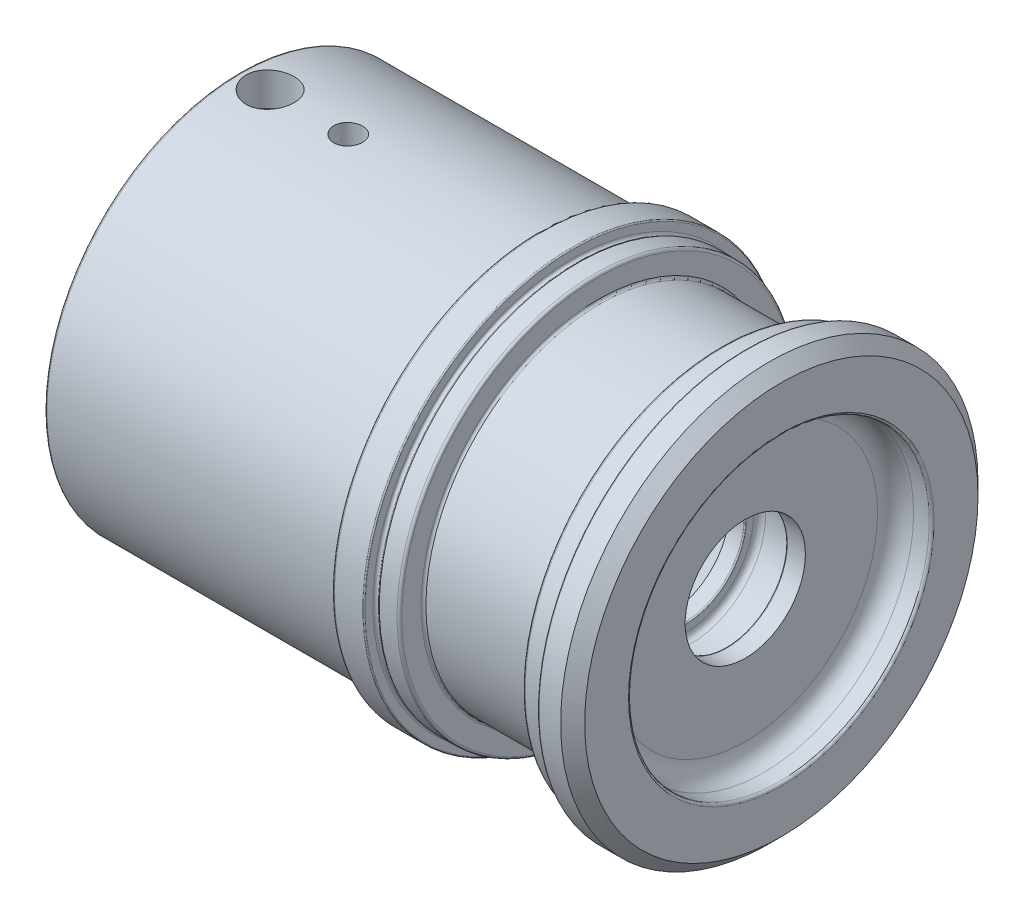
from build123d import *

# Parameters (mm, degrees)
SKETCH2_R          = 4
CUT_EXTRUDE2_DEPTH = 40.5
SKETCH3_R          = 2.4
CUT_EXTRUDE3_DEPTH = 40.5


with BuildPart() as part:
    # Sketch1 → Base-Revolve (revolve)
    with BuildSketch(Plane.XY):
        with BuildLine():
            Line((0, 25.4), (0, 32.7))
            Line((0, 32.7), (-2, 34.7))
            Line((-2, 34.7), (-5.6, 34.7))
            ThreePointArc((-5.6, 34.7), (-5.741421356, 34.641421356), (-5.8, 34.5))
            Line((-5.8, 34.5), (-5.8, 33.2))
            ThreePointArc((-5.8, 33.2), (-6, 32.853589838), (-6.4, 32.853589838))
            Line((-6.4, 32.853589838), (-6.653589838, 33))
            Line((-6.653589838, 33), (-9.6, 33))
            ThreePointArc((-9.6, 33), (-9.882842712, 32.882842712), (-10, 32.6))
            Line((-10, 32.6), (-10, 29.4))
            ThreePointArc((-10, 29.4), (-10.117157288, 29.117157288), (-10.4, 29))
            Line((-10.4, 29), (-30.1, 29))
            ThreePointArc((-30.1, 29), (-30.382842712, 29.117157288), (-30.5, 29.4))
            Line((-30.5, 29.4), (-30.5, 32.6))
            ThreePointArc((-30.5, 32.6), (-30.617157288, 32.882842712), (-30.9, 33))
            Line((-30.9, 33), (-33.846410162, 33))
            Line((-33.846410162, 33), (-34.1, 32.853589838))
            ThreePointArc((-34.1, 32.853589838), (-34.5, 32.853589838), (-34.7, 33.2))
            Line((-34.7, 33.2), (-34.7, 34.5))
            ThreePointArc((-34.7, 34.5), (-34.758578644, 34.641421356), (-34.9, 34.7))
            Line((-34.9, 34.7), (-39.6, 34.7))
            ThreePointArc((-39.6, 34.7), (-39.882842712, 34.582842712), (-40, 34.3))
            Line((-40, 34.3), (-40, 32.9))
            ThreePointArc((-40, 32.9), (-40.117157288, 32.617157288), (-40.4, 32.5))
            Line((-40.4, 32.5), (-89.6, 32.5))
            ThreePointArc((-89.6, 32.5), (-89.882842712, 32.382842712), (-90, 32.1))
            Line((-90, 32.1), (-90, 27.4))
            ThreePointArc((-90, 27.4), (-89.882842712, 27.117157288), (-89.6, 27))
            Line((-89.6, 27), (-80, 27))
            Line((-80, 27), (-80, 25))
            Line((-80, 25), (-63, 25))
            Line((-63, 25), (-59.393004193, 22.9175))
            Line((-59.393004193, 22.9175), (-29.723131212, 22.9175))
            Line((-29.723131212, 22.9175), (-29, 22.5))
            Line((-29, 22.5), (-23.4, 22.5))
            ThreePointArc((-23.4, 22.5), (-23.117157288, 22.382842712), (-23, 22.1))
            Line((-23, 22.1), (-23, 12.5))
            Line((-23, 12.5), (-18.669872981, 10))
            Line((-18.669872981, 10), (-16.2, 10))
            ThreePointArc((-16.2, 10), (-16.058578644, 10.058578644), (-16, 10.2))
            Line((-16, 10.2), (-16, 11.4))
            ThreePointArc((-16, 11.4), (-15.707106781, 12.107106781), (-15, 12.4))
            Line((-15, 12.4), (-10.2, 12.4))
            ThreePointArc((-10.2, 12.4), (-9.492893219, 12.107106781), (-9.2, 11.4))
            Line((-9.2, 11.4), (-9.2, 10.2))
            ThreePointArc((-9.2, 10.2), (-9.141421356, 10.058578644), (-9, 10))
            Line((-9, 10), (-6, 10))
            Line((-6, 10), (-6, 22))
            ThreePointArc((-6, 22), (-5.121320344, 24.121320344), (-3, 25))
            Line((-3, 25), (-0.4, 25))
            ThreePointArc((-0.4, 25), (-0.117157288, 25.117157288), (0, 25.4))
        make_face()
    revolve(axis=Axis((0, 0, 0), (-1, 0, 0)))

    # Sketch2 → Cut-Extrude2 (cut, symmetric)
    with BuildSketch(Plane(origin=(0, 0, 0), x_dir=(1, 0, 0), z_dir=(0, 1, 0))):
        with Locations((-85, 0)):
            Circle(SKETCH2_R)
    extrude(amount=CUT_EXTRUDE2_DEPTH, both=True, mode=Mode.SUBTRACT)

    # Sketch3 → Cut-Extrude3 (cut)
    with BuildSketch(Plane(origin=(0, 0, 0), x_dir=(1, 0, 0), z_dir=(0, 1, 0))):
        with Locations((-72, 0)):
            Circle(SKETCH3_R)
    extrude(amount=CUT_EXTRUDE3_DEPTH, mode=Mode.SUBTRACT)


solid = part.part
